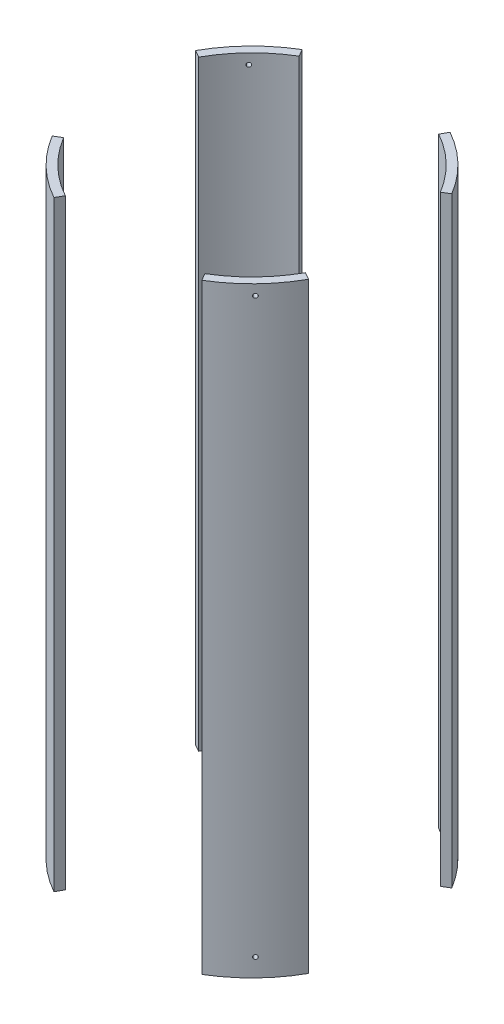
from build123d import *

# Parameters (mm, degrees)
SKETCH2_R               = 88.9
SKETCH2_R_2             = 83.82
BOSS_EXTRUDE1_DEPTH     = 183.48833
CUT_EXTRUDE1_DEPTH      = 184.48833
CUT_EXTRUDE1_DEPTH_BACK = 184.48833
SKETCH5_R               = 1.27
BOLT_HOLES_DEPTH        = 29.911624556
BOLT_PATTERN_COUNT      = 4


with BuildPart() as part:
    # Sketch2 → Boss-Extrude1 (new body, symmetric)
    with BuildSketch(Plane(origin=(0, 0, 0), x_dir=(1, 0, 0), z_dir=(0, 1, 0))):
        Circle(SKETCH2_R)
        Circle(SKETCH2_R_2, mode=Mode.SUBTRACT)
    extrude(amount=BOSS_EXTRUDE1_DEPTH, both=True)

    # Sketch3 → Cut-Extrude1 (cut, two sides)
    with BuildSketch(Plane(origin=(0, 0, 0), x_dir=(1, 0, 0), z_dir=(0, 1, 0))) as cut_extrude1_sk:
        Polygon((169.661755759, -94.300371224), (0, 0), (169.661755759, 101.677593364), align=None)
        Polygon((0, 0), (53.900027233, 96.974944394), (-58.116685864, 96.974944394), align=None)
        Polygon((-123.741299607, 68.777140945), (-123.741299607, -74.157652604), (0, 0), align=None)
        Polygon((-65.840936026, -118.45858783), (0, 0), (70.991745134, -118.45858783), align=None)
    extrude(amount=CUT_EXTRUDE1_DEPTH, mode=Mode.SUBTRACT)
    extrude(cut_extrude1_sk.sketch, amount=-CUT_EXTRUDE1_DEPTH_BACK, mode=Mode.SUBTRACT)

    # Sketch5 → Bolt holes (cut, through all)
    with BuildSketch(Plane(origin=(-56.309218645, 0, 58.175814955), x_dir=(-0.718540152, 0, -0.695485478), z_dir=(0.695485478, 0, -0.718540152))):
        with Locations((-0.02278764, 177.13833)):
            Circle(SKETCH5_R)
        with Locations((-0.02278764, -172.37583)):
            Circle(SKETCH5_R)
    bolt_holes = extrude(amount=-BOLT_HOLES_DEPTH, mode=Mode.SUBTRACT)

    # Bolt pattern: Bolt holes ×4 about axis
    bolt_pattern_axis = Axis((0, 183.48833, 0), (0, 1, 0))
    for i in range(1, BOLT_PATTERN_COUNT):
        add(bolt_holes.rotate(bolt_pattern_axis, i * 360 / BOLT_PATTERN_COUNT), mode=Mode.SUBTRACT)


solid = part.part
